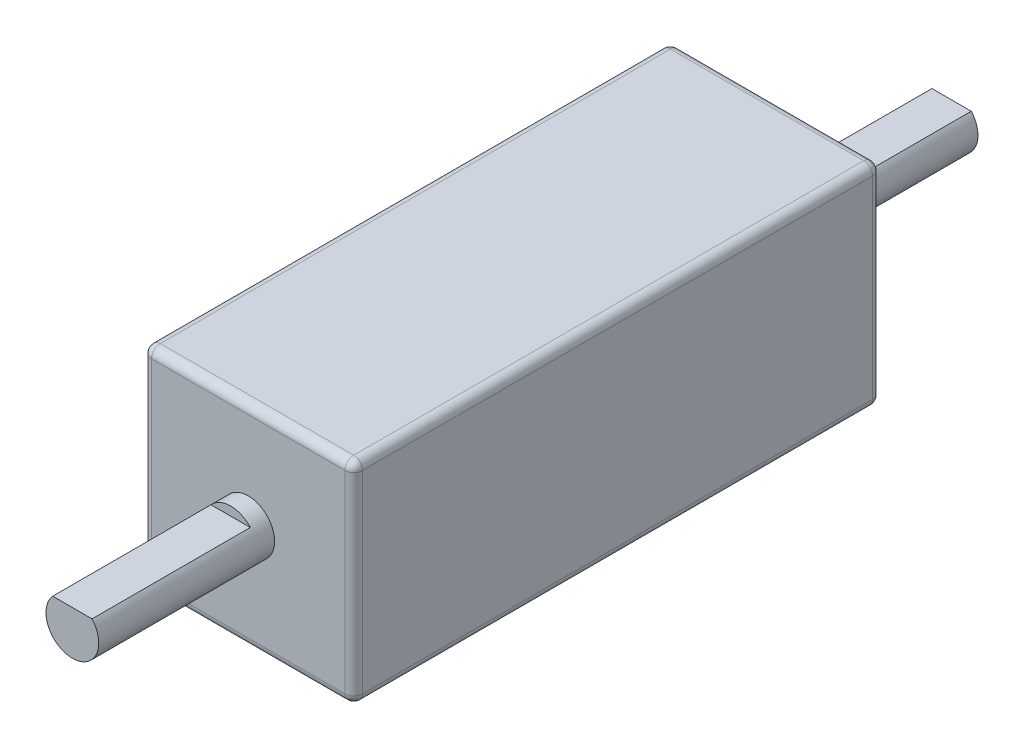
from build123d import *

# Parameters (mm, degrees)
SKETCH_1_W               = 12
SKETCH_1_H               = 12
EXTRUDE_1_DEPTH          = 30
SKETCH_2_R               = 1.5
EXTRUDE_2_DEPTH          = 10
FILLET_1_R               = 0.5
CUT_EXTRUDE_1_DEPTH      = 1
CUT_EXTRUDE_1_DEPTH_BACK = 9
SKETCH_4_R               = 1.5
EXTRUDE_3_DEPTH          = 10
CUT_EXTRUDE_3_DEPTH      = 1
CUT_EXTRUDE_3_DEPTH_BACK = 9


with BuildPart() as part:
    # 草图1 → 凸台-拉伸1 (new body)
    with BuildSketch(Plane.XY):
        Rectangle(SKETCH_1_W, SKETCH_1_H)
    extrude(amount=EXTRUDE_1_DEPTH)

    # 草图2 → 凸台-拉伸2 (add)
    with BuildSketch(Plane.XY.offset(30)):
        Circle(SKETCH_2_R)
    extrude(amount=EXTRUDE_2_DEPTH)

    # 圆角1
    fillet_1_edges = [part.edges().sort_by_distance(p)[0] for p in [
        (-6, 0, 30),
        (0, -6, 30),
        (6, 0, 30),
        (0, -6, 0),
        (-6, 0, 0),
        (0, 6, 0),
        (6, 0, 0),
        (6, -6, 15),
        (-6, -6, 15),
        (-6, 6, 15),
        (6, 6, 15),
        (0, 6, 30),
    ]]
    fillet(fillet_1_edges, radius=FILLET_1_R)

    # 草图3 → 切除-拉伸1 (cut, two sides)
    with BuildSketch(Plane.XY.offset(40)) as cut_extrude_1_sk:
        Polygon((-31.084646908, 1), (-1.118033989, 1), (1.118033989, 1), (31.084646908, 1), (31.084646908, 60.933225838), (-31.084646908, 60.933225838), align=None)
    extrude(amount=CUT_EXTRUDE_1_DEPTH, mode=Mode.SUBTRACT)
    extrude(cut_extrude_1_sk.sketch, amount=-CUT_EXTRUDE_1_DEPTH_BACK, mode=Mode.SUBTRACT)

    # 草图4 → 凸台-拉伸3 (add)
    with BuildSketch(Plane(origin=(0, 0, 0), x_dir=(-1, 0, 0), z_dir=(0, 0, -1))):
        Circle(SKETCH_4_R)
    extrude(amount=EXTRUDE_3_DEPTH)

    # 草图5 → 切除-拉伸3 (cut, two sides)
    with BuildSketch(Plane(origin=(0, 0, -10), x_dir=(-1, 0, 0), z_dir=(0, 0, -1))) as cut_extrude_3_sk:
        Polygon((31.084646908, 1), (1.118033989, 1), (-1.118033989, 1), (-31.084646908, 1), (-31.084646908, 60.933225838), (31.084646908, 60.933225838), align=None)
    extrude(amount=CUT_EXTRUDE_3_DEPTH, mode=Mode.SUBTRACT)
    extrude(cut_extrude_3_sk.sketch, amount=-CUT_EXTRUDE_3_DEPTH_BACK, mode=Mode.SUBTRACT)


solid = part.part
